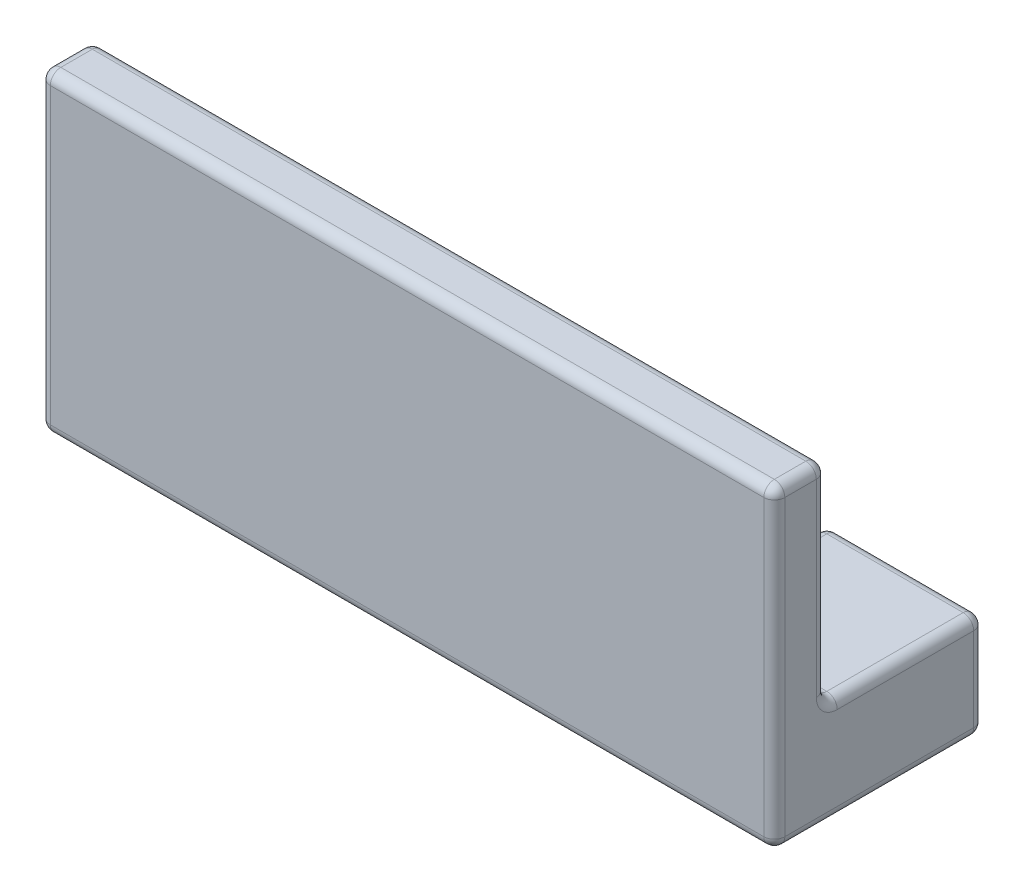
from build123d import *

# Parameters (mm, degrees)
SKETCH1_W           = 70
SKETCH1_H           = 5
BOSS_EXTRUDE1_DEPTH = 30
SKETCH4_W           = 70
SKETCH4_H           = 15
BOSS_EXTRUDE2_DEPTH = 10
SKETCH5_W           = 4
SKETCH5_H           = 10
CUT_EXTRUDE1_DEPTH  = 10
SKETCH6_W           = 4
SKETCH6_H           = 10
CUT_EXTRUDE2_DEPTH  = 10
SKETCH7_W           = 4
SKETCH7_H           = 10
CUT_EXTRUDE3_DEPTH  = 10
SKETCH8_W           = 4
SKETCH8_H           = 10
CUT_EXTRUDE4_DEPTH  = 10
FILLET5_R           = 1


with BuildPart() as part:
    # Sketch1 → Boss-Extrude1 (new body)
    with BuildSketch(Plane(origin=(0, 0, 0), x_dir=(1, 0, 0), z_dir=(0, 1, 0))):
        with Locations((35, 2.5)):
            Rectangle(SKETCH1_W, SKETCH1_H)
    extrude(amount=BOSS_EXTRUDE1_DEPTH)

    # Sketch4 → Boss-Extrude2 (add)
    with BuildSketch(Plane(origin=(0, 0, 0), x_dir=(-1, 0, 0), z_dir=(0, -1, 0))):
        with Locations((-35, 12.5)):
            Rectangle(SKETCH4_W, SKETCH4_H)
    extrude(amount=-BOSS_EXTRUDE2_DEPTH)

    # Sketch5 → Cut-Extrude1 (cut)
    with BuildSketch(Plane(origin=(0, 10, 0), x_dir=(1, 0, 0), z_dir=(0, 1, 0))):
        with Locations((17, 15)):
            Rectangle(SKETCH5_W, SKETCH5_H)
    extrude(amount=-CUT_EXTRUDE1_DEPTH, mode=Mode.SUBTRACT)

    # Sketch6 → Cut-Extrude2 (cut)
    with BuildSketch(Plane(origin=(0, 10, 0), x_dir=(1, 0, 0), z_dir=(0, 1, 0))):
        with Locations((29, 15)):
            Rectangle(SKETCH6_W, SKETCH6_H)
    extrude(amount=-CUT_EXTRUDE2_DEPTH, mode=Mode.SUBTRACT)

    # Sketch7 → Cut-Extrude3 (cut)
    with BuildSketch(Plane(origin=(0, 10, 0), x_dir=(1, 0, 0), z_dir=(0, 1, 0))):
        with Locations((41, 15)):
            Rectangle(SKETCH7_W, SKETCH7_H)
    extrude(amount=-CUT_EXTRUDE3_DEPTH, mode=Mode.SUBTRACT)

    # Sketch8 → Cut-Extrude4 (cut)
    with BuildSketch(Plane(origin=(0, 10, 0), x_dir=(1, 0, 0), z_dir=(0, 1, 0))):
        with Locations((53, 15)):
            Rectangle(SKETCH8_W, SKETCH8_H)
    extrude(amount=-CUT_EXTRUDE4_DEPTH, mode=Mode.SUBTRACT)

    # Fillet5
    fillet5_edges = [part.edges().sort_by_distance(p)[0] for p in [
        (70, 30, -2.5),
        (35, 30, -5),
        (62.5, 0, -20),
        (70, 5, -20),
        (0, 10, -12.5),
        (0, 5, -20),
        (35, 10, -5),
        (70, 10, -12.5),
        (62.5, 10, -20),
        (7.5, 10, -20),
        (7.5, 0, -20),
        (15, 5, -20),
        (19, 10, -15),
        (19, 5, -20),
        (17, 0, -10),
        (15, 0, -15),
        (19, 0, -15),
        (15, 10, -15),
        (17, 10, -10),
        (0, 30, -2.5),
        (23, 10, -20),
        (23, 0, -20),
        (27, 0, -15),
        (27, 5, -20),
        (31, 0, -15),
        (31, 5, -20),
        (29, 0, -10),
        (27, 10, -15),
        (29, 10, -10),
        (31, 10, -15),
        (70, 0, -10),
        (35, 0, 0),
        (0, 0, -10),
        (35, 10, -20),
        (35, 0, -20),
        (39, 0, -15),
        (39, 5, -20),
        (43, 0, -15),
        (43, 5, -20),
        (41, 0, -10),
        (39, 10, -15),
        (41, 10, -10),
        (43, 10, -15),
        (35, 30, 0),
        (47, 10, -20),
        (0, 20, -5),
        (47, 0, -20),
        (70, 20, -5),
        (70, 15, 0),
        (0, 15, 0),
        (51, 0, -15),
        (51, 5, -20),
        (55, 0, -15),
        (55, 5, -20),
        (53, 0, -10),
        (51, 10, -15),
        (53, 10, -10),
        (55, 10, -15),
    ]]
    fillet(fillet5_edges, radius=FILLET5_R)


solid = part.part
